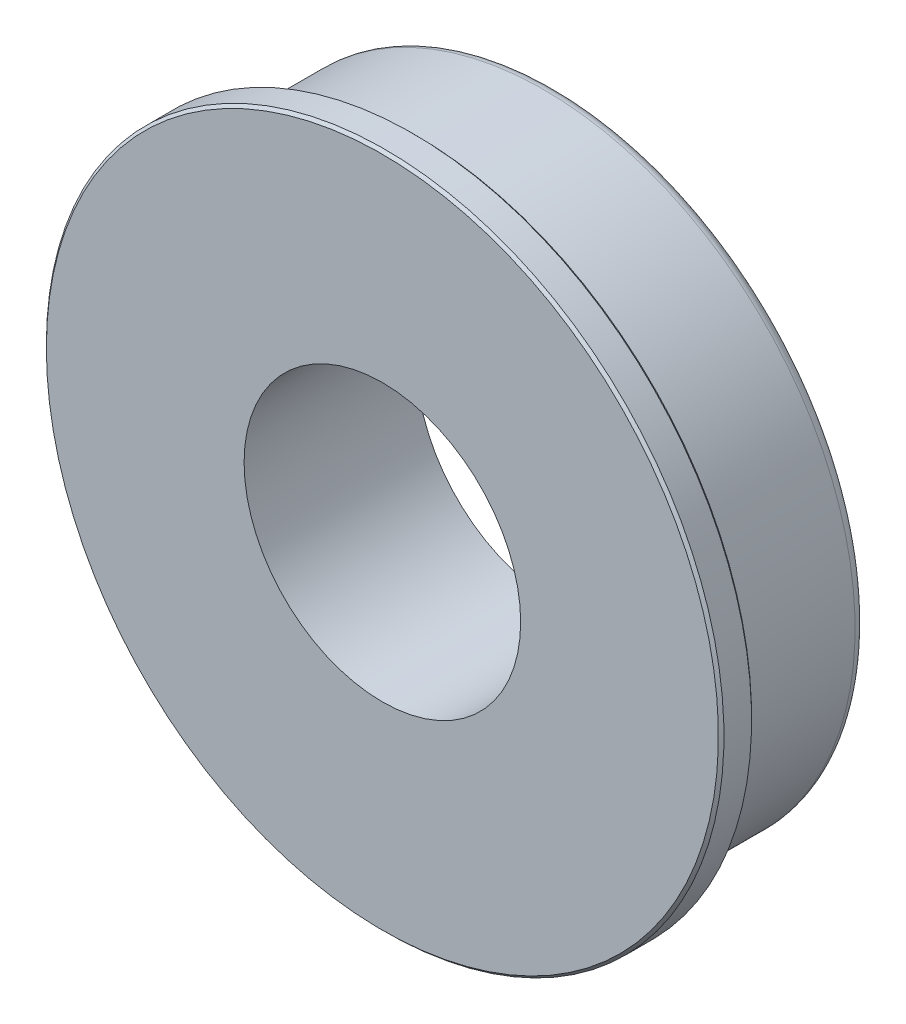
from build123d import *


with BuildPart() as part:
    # Sketch1 → Revolve1 (revolve)
    with BuildSketch(Plane.XZ):
        with BuildLine():
            Line((14.2875, 0.508), (14.2875, 5.89534))
            Line((14.2875, 5.89534), (13.97, 5.89534))
            Line((13.97, 5.89534), (13.97, 6.40334))
            Line((13.97, 6.40334), (15.4305, 6.40334))
            Line((15.4305, 6.40334), (15.5575, 6.53034))
            Line((15.5575, 6.53034), (15.5575, 7.80034))
            Line((15.5575, 7.80034), (15.4305, 7.92734))
            Line((15.4305, 7.92734), (6.35, 7.92734))
            Line((6.35, 7.92734), (6.35, 0))
            Line((6.35, 0), (13.7795, 0))
            ThreePointArc((13.7795, 0), (14.138710245, 0.148789755), (14.2875, 0.508))
        make_face()
    revolve(axis=Axis((0, 0, 7.92734), (0, 0, -1)))


solid = part.part
